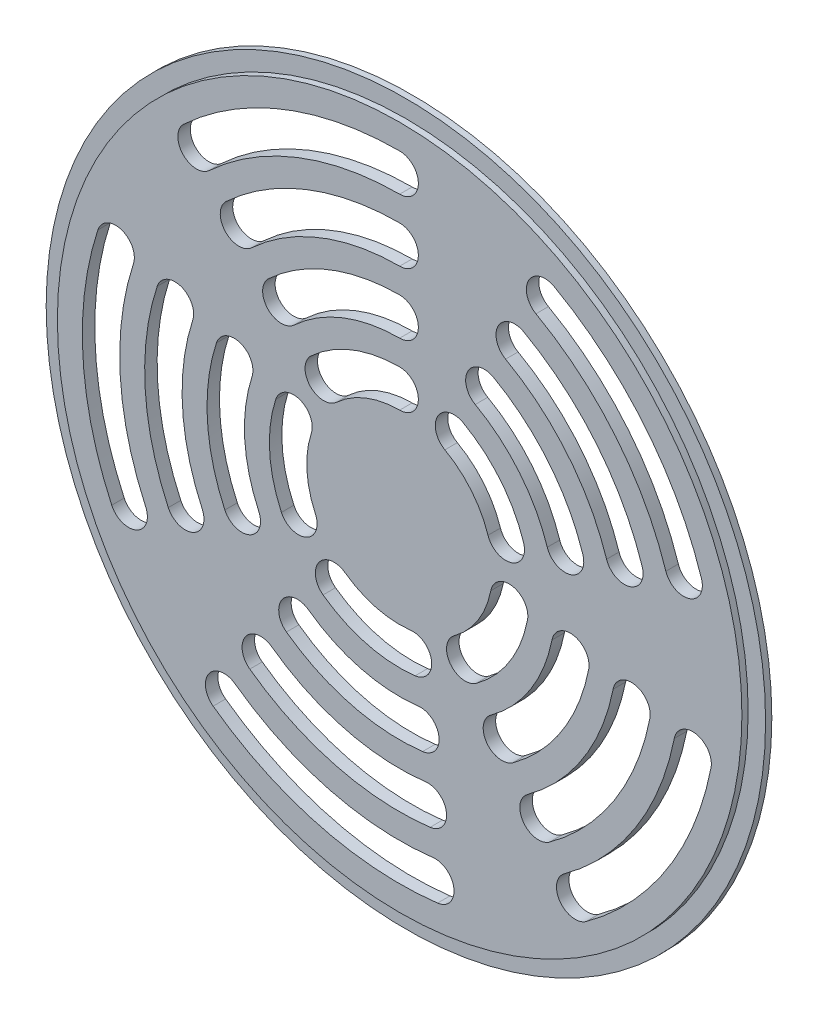
from build123d import *

# Parameters (mm, degrees)
ESQUISSE1_R        = 54.9
BOSS_EXTRU_1_DEPTH = 2
ESQUISSE3_R        = 57.7
ESQUISSE3_R_2      = 54.9
BOSS_EXTRU_2_DEPTH = 1


with BuildPart() as part:
    # Esquisse1 → Boss.-Extru.1 (new body)
    with BuildSketch(Plane.XY):
        Circle(ESQUISSE1_R)
        with BuildLine():
            ThreePointArc((6.077539891, -50.535863591), (-12.805584053, -49.262836064), (-29.918269342, -41.178965014))
            ThreePointArc((-29.918269342, -41.178965014), (-30.581964568, -36.988558274), (-26.391557828, -36.324863047))
            ThreePointArc((-26.391557828, -36.324863047), (-11.29608495, -43.45582199), (5.361130473, -44.578787333))
            ThreePointArc((5.361130473, -44.578787333), (7.709986567, -45.312930875), (8.719335182, -47.557325462))
            ThreePointArc((8.719335182, -47.557325462), (7.963729769, -49.547976847), (6.077539891, -50.535863591))
        make_face(mode=Mode.SUBTRACT)
        with BuildLine():
            ThreePointArc((4.883524195, -40.60740316), (-10.289752215, -39.584479273), (-24.040416819, -33.08879507))
            ThreePointArc((-24.040416819, -33.08879507), (-24.704112045, -28.89838833), (-20.513705305, -28.234693104))
            ThreePointArc((-20.513705305, -28.234693104), (-8.780253113, -33.777465199), (4.167114778, -34.650326902))
            ThreePointArc((4.167114778, -34.650326902), (6.515970872, -35.384470444), (7.525319487, -37.628865031))
            ThreePointArc((7.525319487, -37.628865031), (6.769714074, -39.619516416), (4.883524195, -40.60740316))
        make_face(mode=Mode.SUBTRACT)
        with BuildLine():
            ThreePointArc((-46.184399264, -21.396524591), (-50.808884345, -3.044219377), (-48.408776679, 15.728965014))
            ThreePointArc((-48.408776679, 15.728965014), (-45.086303735, 17.764979052), (-42.555607131, 14.801914031))
            ThreePointArc((-42.555607131, 14.801914031), (-42.592542109, 14.332610635), (-42.702437582, 13.874863047))
            ThreePointArc((-42.702437582, 13.874863047), (-44.819624894, -2.685372299), (-40.740265756, -18.874340946))
            ThreePointArc((-40.740265756, -18.874340946), (-40.532639671, -19.489754932), (-40.46233251, -20.135432769))
            ThreePointArc((-40.46233251, -20.135432769), (-42.816654674, -23.065125608), (-46.184399264, -21.396524591))
        make_face(mode=Mode.SUBTRACT)
        with BuildLine():
            ThreePointArc((-37.110843417, -17.192885182), (-40.82678526, -2.446140914), (-38.898211516, 12.63879507))
            ThreePointArc((-38.898211516, 12.63879507), (-35.575738572, 14.674809109), (-33.045041968, 11.711744087))
            ThreePointArc((-33.045041968, 11.711744087), (-33.081976946, 11.242440692), (-33.191872419, 10.784693104))
            ThreePointArc((-33.191872419, 10.784693104), (-34.837525808, -2.087293836), (-31.666709908, -14.670701537))
            ThreePointArc((-31.666709908, -14.670701537), (-31.459083823, -15.286115523), (-31.388776663, -15.93179336))
            ThreePointArc((-31.388776663, -15.93179336), (-33.743098826, -18.861486199), (-37.110843417, -17.192885182))
        make_face(mode=Mode.SUBTRACT)
        with BuildLine():
            ThreePointArc((3.6895085, -30.67894273), (-7.773920378, -29.906122483), (-18.162564296, -24.998625126))
            ThreePointArc((-18.162564296, -24.998625126), (-18.826259522, -20.808218386), (-14.635852782, -20.14452316))
            ThreePointArc((-14.635852782, -20.14452316), (-6.264421275, -24.099108409), (2.973099082, -24.721866472))
            ThreePointArc((2.973099082, -24.721866472), (5.321955176, -25.456010014), (6.331303791, -27.700404601))
            ThreePointArc((6.331303791, -27.700404601), (5.575698378, -29.691055986), (3.6895085, -30.67894273))
        make_face(mode=Mode.SUBTRACT)
        with BuildLine():
            ThreePointArc((2.495492804, -20.7504823), (-5.25808854, -20.227765692), (-12.284711773, -16.908455182))
            ThreePointArc((-12.284711773, -16.908455182), (-12.948406999, -12.718048442), (-8.758000259, -12.054353216))
            ThreePointArc((-8.758000259, -12.054353216), (-3.748589438, -14.420751618), (1.779083387, -14.793406041))
            ThreePointArc((1.779083387, -14.793406041), (4.12793948, -15.527549583), (5.137288095, -17.77194417))
            ThreePointArc((5.137288095, -17.77194417), (4.381682682, -19.762595556), (2.495492804, -20.7504823))
        make_face(mode=Mode.SUBTRACT)
        with BuildLine():
            ThreePointArc((-28.037287569, -12.989245773), (-30.844686174, -1.848062451), (-29.387646354, 9.548625126))
            ThreePointArc((-29.387646354, 9.548625126), (-26.06517341, 11.584639165), (-23.534476805, 8.621574143))
            ThreePointArc((-23.534476805, 8.621574143), (-23.571411783, 8.152270748), (-23.681307256, 7.69452316))
            ThreePointArc((-23.681307256, 7.69452316), (-24.855426723, -1.489215373), (-22.593154061, -10.467062128))
            ThreePointArc((-22.593154061, -10.467062128), (-22.385527976, -11.082476114), (-22.315220815, -11.728153951))
            ThreePointArc((-22.315220815, -11.728153951), (-24.669542978, -14.65784679), (-28.037287569, -12.989245773))
        make_face(mode=Mode.SUBTRACT)
        with BuildLine():
            ThreePointArc((-18.963731722, -8.785606365), (-20.862587089, -1.249983988), (-19.877081191, 6.458455182))
            ThreePointArc((-19.877081191, 6.458455182), (-16.554608247, 8.494469221), (-14.023911642, 5.531404199))
            ThreePointArc((-14.023911642, 5.531404199), (-14.06084662, 5.062100804), (-14.170742093, 4.604353216))
            ThreePointArc((-14.170742093, 4.604353216), (-14.873327637, -0.89113691), (-13.519598213, -6.263422719))
            ThreePointArc((-13.519598213, -6.263422719), (-13.311972128, -6.878836705), (-13.241664967, -7.524514542))
            ThreePointArc((-13.241664967, -7.524514542), (-15.595987131, -10.454207381), (-18.963731722, -8.785606365))
        make_face(mode=Mode.SUBTRACT)
        with BuildLine():
            ThreePointArc((30.317529224, -5.971383573), (26.040139155, -16.634937716), (18.162564296, -24.998625126))
            ThreePointArc((18.162564296, -24.998625126), (13.972157556, -24.3349299), (14.635852782, -20.14452316))
            ThreePointArc((14.635852782, -20.14452316), (20.983801455, -13.404852722), (24.430630345, -4.811891617))
            ThreePointArc((24.430630345, -4.811891617), (27.665328546, -2.405808705), (30.374079784, -5.391637595))
            ThreePointArc((30.374079784, -5.391637595), (30.359908674, -5.682886356), (30.317529224, -5.971383573))
        make_face(mode=Mode.SUBTRACT)
        with BuildLine():
            ThreePointArc((20.506031093, -4.03889698), (17.612909655, -11.251462727), (12.284711773, -16.908455182))
            ThreePointArc((12.284711773, -16.908455182), (8.094305033, -16.244759956), (8.758000259, -12.054353216))
            ThreePointArc((8.758000259, -12.054353216), (12.556571955, -8.021377733), (14.619132215, -2.879405024))
            ThreePointArc((14.619132215, -2.879405024), (17.853830416, -0.473322112), (20.562581654, -3.459151002))
            ThreePointArc((20.562581654, -3.459151002), (20.548410544, -3.750399763), (20.506031093, -4.03889698))
        make_face(mode=Mode.SUBTRACT)
        with BuildLine():
            ThreePointArc((49.940525485, -9.836356759), (42.894598155, -27.401887693), (29.918269342, -41.178965014))
            ThreePointArc((29.918269342, -41.178965014), (25.727862602, -40.515269787), (26.391557828, -36.324863047))
            ThreePointArc((26.391557828, -36.324863047), (37.838260455, -24.1718027), (44.053626607, -8.676864803))
            ThreePointArc((44.053626607, -8.676864803), (47.288324808, -6.270781891), (49.997076046, -9.256610781))
            ThreePointArc((49.997076046, -9.256610781), (49.982904936, -9.547859543), (49.940525485, -9.836356759))
        make_face(mode=Mode.SUBTRACT)
        with BuildLine():
            ThreePointArc((40.129027354, -7.903870166), (34.467368655, -22.018412704), (24.040416819, -33.08879507))
            ThreePointArc((24.040416819, -33.08879507), (19.850010079, -32.425099844), (20.513705305, -28.234693104))
            ThreePointArc((20.513705305, -28.234693104), (29.411030955, -18.788327711), (34.242128476, -6.74437821))
            ThreePointArc((34.242128476, -6.74437821), (37.476826677, -4.338295298), (40.185577915, -7.324124188))
            ThreePointArc((40.185577915, -7.324124188), (40.171406805, -7.615372949), (40.129027354, -7.903870166))
        make_face(mode=Mode.SUBTRACT)
        with BuildLine():
            ThreePointArc((-14.215723561, 15.320678955), (-7.635699374, 19.455233103), (0, 20.9))
            ThreePointArc((0, 20.9), (2.121320344, 20.021320344), (3, 17.9))
            ThreePointArc((3, 17.9), (2.121320344, 15.778679656), (0, 14.9))
            ThreePointArc((0, 14.9), (-5.443632568, 13.869998719), (-10.134654596, 10.922397915))
            ThreePointArc((-10.134654596, 10.922397915), (-14.374329599, 11.081003952), (-14.215723561, 15.320678955))
        make_face(mode=Mode.SUBTRACT)
        with BuildLine():
            ThreePointArc((-21.01750517, 22.651147354), (-11.28914405, 28.763957075), (0, 30.9))
            ThreePointArc((0, 30.9), (2.121320344, 30.021320344), (3, 27.9))
            ThreePointArc((3, 27.9), (2.121320344, 25.778679656), (0, 24.9))
            ThreePointArc((0, 24.9), (-9.097077244, 23.178722692), (-16.936436205, 18.252866314))
            ThreePointArc((-16.936436205, 18.252866314), (-21.176111207, 18.411472352), (-21.01750517, 22.651147354))
        make_face(mode=Mode.SUBTRACT)
        with BuildLine():
            ThreePointArc((-27.819286778, 29.981615753), (-14.942588727, 38.072681048), (0, 40.9))
            ThreePointArc((0, 40.9), (2.121320344, 40.021320344), (3, 37.9))
            ThreePointArc((3, 37.9), (2.121320344, 35.778679656), (0, 34.9))
            ThreePointArc((0, 34.9), (-12.750521921, 32.487446664), (-23.738217813, 25.583334713))
            ThreePointArc((-23.738217813, 25.583334713), (-27.977892815, 25.741940751), (-27.819286778, 29.981615753))
        make_face(mode=Mode.SUBTRACT)
        with BuildLine():
            ThreePointArc((-34.621068386, 37.312084152), (-18.596033403, 47.38140502), (0, 50.9))
            ThreePointArc((0, 50.9), (2.121320344, 50.021320344), (3, 47.9))
            ThreePointArc((3, 47.9), (2.121320344, 45.778679656), (0, 44.9))
            ThreePointArc((0, 44.9), (-16.403966597, 41.796170637), (-30.539999421, 32.913803113))
            ThreePointArc((-30.539999421, 32.913803113), (-34.779674424, 33.07240915), (-34.621068386, 37.312084152))
        make_face(mode=Mode.SUBTRACT)
        with BuildLine():
            ThreePointArc((10.177931386, 18.254306689), (16.143465348, 13.273979304), (19.877081191, 6.458455182))
            ThreePointArc((19.877081191, 6.458455182), (19.986976663, 6.000707594), (20.023911642, 5.531404199))
            ThreePointArc((20.023911642, 5.531404199), (17.493215037, 2.568339178), (14.170742093, 4.604353216))
            ThreePointArc((14.170742093, 4.604353216), (11.508977688, 9.463267542), (7.256037208, 13.013835869))
            ThreePointArc((7.256037208, 13.013835869), (6.096748887, 17.095018368), (10.177931386, 18.254306689))
        make_face(mode=Mode.SUBTRACT)
        with BuildLine():
            ThreePointArc((15.047755016, 26.988424722), (23.867611447, 19.625165574), (29.387646354, 9.548625126))
            ThreePointArc((29.387646354, 9.548625126), (29.497541826, 9.090877538), (29.534476805, 8.621574143))
            ThreePointArc((29.534476805, 8.621574143), (27.0037802, 5.658509121), (23.681307256, 7.69452316))
            ThreePointArc((23.681307256, 7.69452316), (19.233123788, 15.814453812), (12.125860838, 21.747953902))
            ThreePointArc((12.125860838, 21.747953902), (10.966572517, 25.829136401), (15.047755016, 26.988424722))
        make_face(mode=Mode.SUBTRACT)
        with BuildLine():
            ThreePointArc((19.917578645, 35.722542755), (31.591757547, 25.976351844), (38.898211516, 12.63879507))
            ThreePointArc((38.898211516, 12.63879507), (39.008106989, 12.181047482), (39.045041968, 11.711744087))
            ThreePointArc((39.045041968, 11.711744087), (36.514345363, 8.748679065), (33.191872419, 10.784693104))
            ThreePointArc((33.191872419, 10.784693104), (26.957269887, 22.165640082), (16.995684467, 30.482071936))
            ThreePointArc((16.995684467, 30.482071936), (15.836396146, 34.563254434), (19.917578645, 35.722542755))
        make_face(mode=Mode.SUBTRACT)
        with BuildLine():
            ThreePointArc((24.787402275, 44.456660789), (39.315903646, 32.327538114), (48.408776679, 15.728965014))
            ThreePointArc((48.408776679, 15.728965014), (48.518672152, 15.271217426), (48.555607131, 14.801914031))
            ThreePointArc((48.555607131, 14.801914031), (46.024910526, 11.838849009), (42.702437582, 13.874863047))
            ThreePointArc((42.702437582, 13.874863047), (34.681415986, 28.516826352), (21.865508097, 39.216189969))
            ThreePointArc((21.865508097, 39.216189969), (20.706219776, 43.297372467), (24.787402275, 44.456660789))
        make_face(mode=Mode.SUBTRACT)
    extrude(amount=BOSS_EXTRU_1_DEPTH)


with BuildPart() as body_2:
    # Esquisse3 → Boss.-Extru.2 (new body)
    with BuildSketch(Plane(origin=(0, 0, 0), x_dir=(-1, 0, 0), z_dir=(0, 0, -1))):
        Circle(ESQUISSE3_R)
        Circle(ESQUISSE3_R_2, mode=Mode.SUBTRACT)
    extrude(amount=-BOSS_EXTRU_2_DEPTH)


solid = Compound([part.part, body_2.part])
